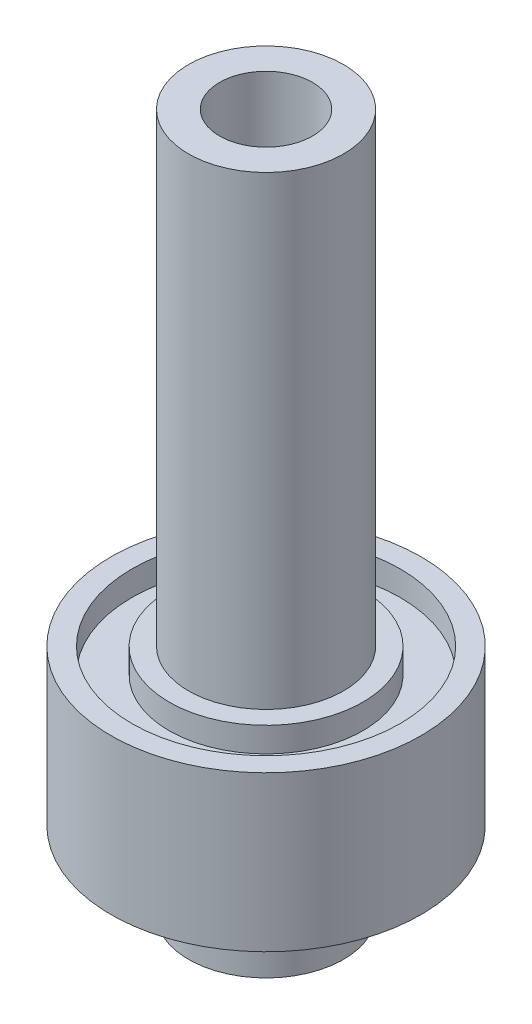
from build123d import *


with BuildPart() as part:
    # Sketch1 → Revolve1 (revolve)
    with BuildSketch(Plane.XY):
        Polygon((-3.81, 0), (-6.35, 0), (-6.35, 6.35), (-12.7, 6.35), (-12.7, 19.05), (-10.9855, 19.05), (-10.9855, 17.018), (-7.9375, 17.018), (-7.9375, 19.05), (-6.35, 19.05), (-6.35, 57.15), (-3.81, 57.15), align=None)
    revolve(axis=Axis((0, 0, 0), (0, 1, 0)))


solid = part.part
